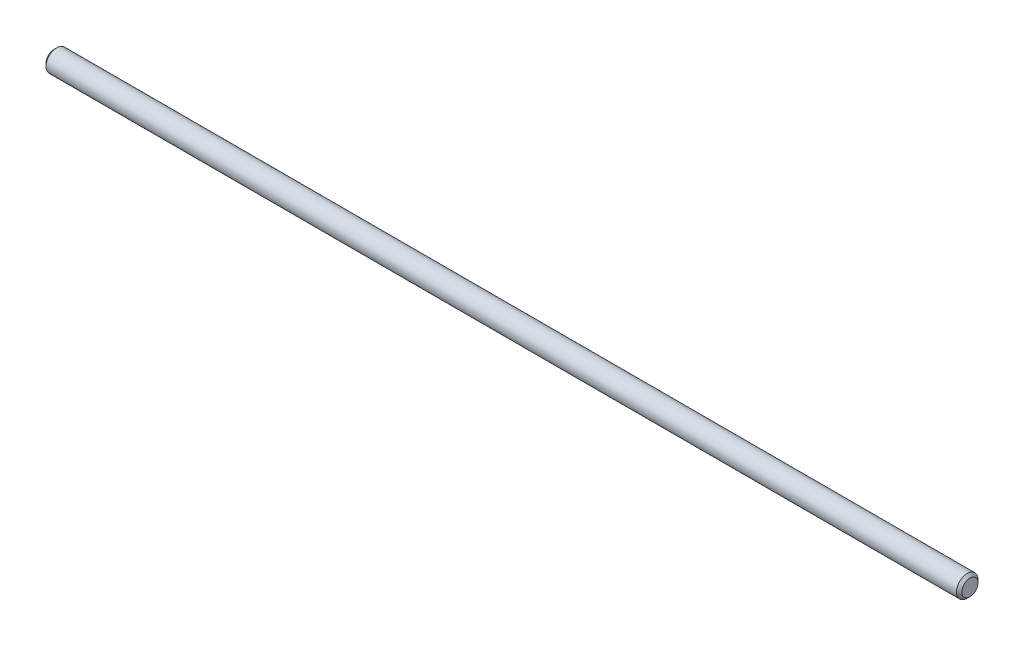
from build123d import *

# Parameters (mm, degrees)
SALIENTE_EXTRUIR1_DEPTH      = 170
SALIENTE_EXTRUIR1_DEPTH_BACK = 170
CROQUIS1_R                   = 4
CHAFL_N1_SIZE                = 1


with BuildPart() as part:
    # Croquis1 → Saliente-Extruir1 (new, two sides: drawn at the far end of the back side and taken through both)
    with BuildSketch(Plane(origin=(0, 0, 0), x_dir=(0, 0, -1), z_dir=(1, 0, 0)).offset(-SALIENTE_EXTRUIR1_DEPTH_BACK)):
        Circle(CROQUIS1_R)
    extrude(amount=SALIENTE_EXTRUIR1_DEPTH + SALIENTE_EXTRUIR1_DEPTH_BACK)

    # Chaflán1
    chafl_n1_edges = [part.edges().sort_by_distance(p)[0] for p in [
        (-170, 0, 4),
        (170, 0, 4),
    ]]
    chamfer(chafl_n1_edges, length=CHAFL_N1_SIZE)


solid = part.part
